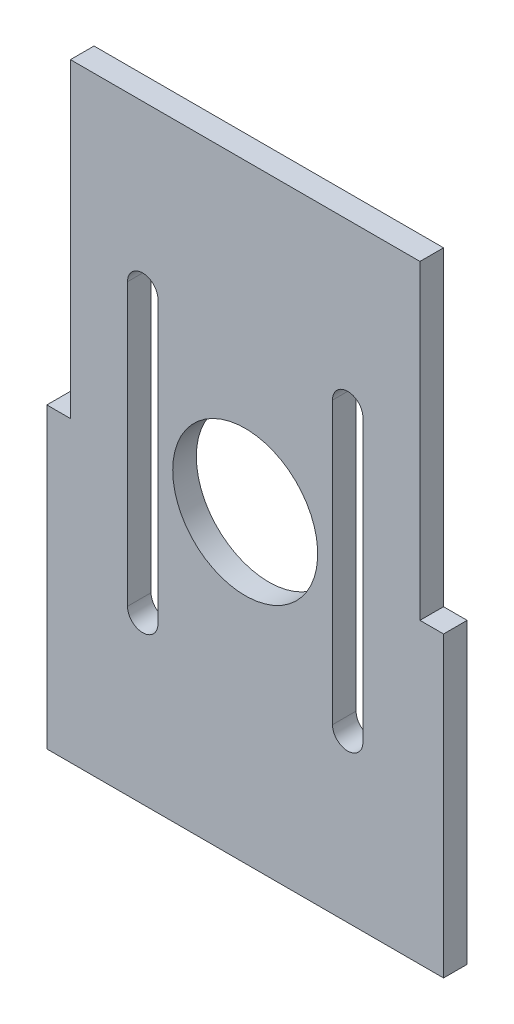
from build123d import *

# Parameters (mm, degrees)
SKETCH5_W           = 45.93
SKETCH5_H           = 80
BOSS_EXTRUDE5_DEPTH = 3.1
SKETCH6_W           = 3.1
SKETCH6_H           = 39.153821237
BOSS_EXTRUDE6_DEPTH = 3.1
SKETCH7_R           = 9.525
CUT_EXTRUDE2_DEPTH  = 4.1


with BuildPart() as part:
    # Sketch5 → Boss-Extrude5 (new body)
    with BuildSketch(Plane.XY):
        Rectangle(SKETCH5_W, SKETCH5_H)
    extrude(amount=BOSS_EXTRUDE5_DEPTH)

    # Sketch6 → Boss-Extrude6 (add, through all)
    with BuildSketch(Plane.XY):
        with Locations((24.515, -20.423089381)):
            Rectangle(SKETCH6_W, SKETCH6_H)
        with Locations((-24.515, -20.423089381)):
            Rectangle(SKETCH6_W, SKETCH6_H)
    extrude(amount=BOSS_EXTRUDE6_DEPTH)

    # Sketch7 → Cut-Extrude2 (cut, through all)
    with BuildSketch(Plane.XY):
        Circle(SKETCH7_R)
        with BuildLine():
            Line((-15.470384182, 13.470384182), (-15.470384182, -13.470384182))
            Line((-15.470384182, -13.470384182), (-15.470384182, -18.470384182))
            ThreePointArc((-15.470384182, -18.470384182), (-13.470384182, -20.470384182), (-11.470384182, -18.470384182))
            Line((-11.470384182, -18.470384182), (-11.470384182, -13.470384182))
            Line((-11.470384182, -13.470384182), (-11.470384182, 13.470384182))
            Line((-11.470384182, 13.470384182), (-11.470384182, 18.470384182))
            ThreePointArc((-11.470384182, 18.470384182), (-13.470384182, 20.470384182), (-15.470384182, 18.470384182))
            Line((-15.470384182, 18.470384182), (-15.470384182, 13.470384182))
        make_face()
        with BuildLine():
            Line((11.470384182, 13.470384182), (11.470384182, 18.470384182))
            ThreePointArc((11.470384182, 18.470384182), (13.470384182, 20.470384182), (15.470384182, 18.470384182))
            Line((15.470384182, 18.470384182), (15.470384182, 13.470384182))
            Line((15.470384182, 13.470384182), (15.470384182, -13.470384182))
            Line((15.470384182, -13.470384182), (15.470384182, -18.470384182))
            ThreePointArc((15.470384182, -18.470384182), (13.470384182, -20.470384182), (11.470384182, -18.470384182))
            Line((11.470384182, -18.470384182), (11.470384182, -13.470384182))
            Line((11.470384182, -13.470384182), (11.470384182, 13.470384182))
        make_face()
    extrude(amount=CUT_EXTRUDE2_DEPTH, mode=Mode.SUBTRACT)


solid = part.part
